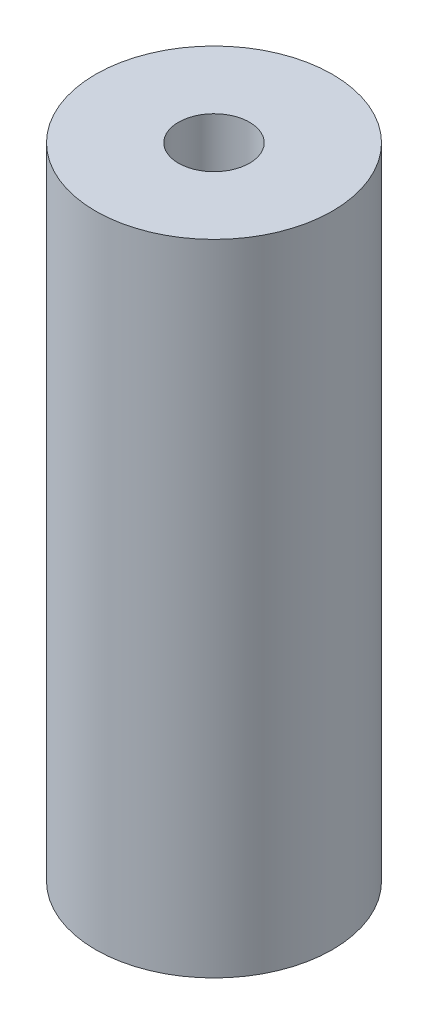
from build123d import *

# Parameters (mm, degrees)
CROQUIS1_R              = 5
SALIENTE_EXTRUIR1_DEPTH = 27
CROQUIS2_R              = 1.5
CORTAR_EXTRUIR1_DEPTH   = 5
CROQUIS4_R              = 1.5
CORTAR_EXTRUIR2_DEPTH   = 5


with BuildPart() as part:
    # Croquis1 → Saliente-Extruir1 (new body)
    with BuildSketch(Plane(origin=(0, 0, 0), x_dir=(1, 0, 0), z_dir=(0, 1, 0))):
        Circle(CROQUIS1_R)
    extrude(amount=SALIENTE_EXTRUIR1_DEPTH)

    # Croquis2 → Cortar-Extruir1 (cut)
    with BuildSketch(Plane(origin=(0, 27, 0), x_dir=(1, 0, 0), z_dir=(0, 1, 0))):
        Circle(CROQUIS2_R)
    extrude(amount=-CORTAR_EXTRUIR1_DEPTH, mode=Mode.SUBTRACT)

    # Croquis4 → Cortar-Extruir2 (cut)
    with BuildSketch(Plane.XZ):
        Circle(CROQUIS4_R)
    extrude(amount=-CORTAR_EXTRUIR2_DEPTH, mode=Mode.SUBTRACT)


solid = part.part
